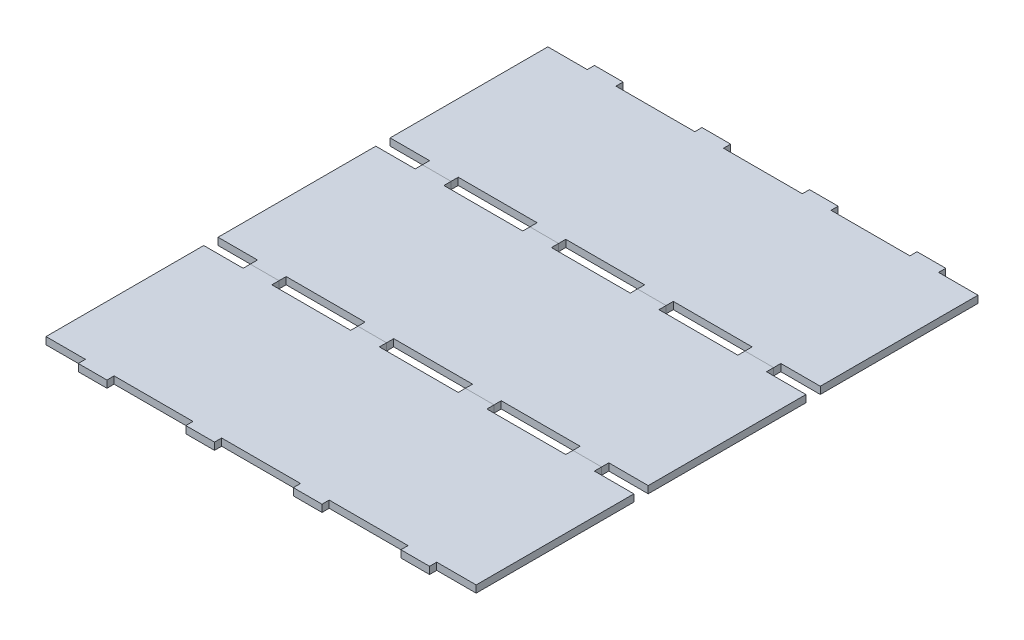
from build123d import *

# Parameters (mm, degrees)
SKETCH1_W               = 381
SKETCH1_H               = 152.4
BOSS_EXTRUDE1_DEPTH     = 6.35
SKETCH2_W               = 69.85
SKETCH2_H               = 6.35
CUT_EXTRUDE2_DEPTH      = 7.35
LPATTERN1_COUNT         = 3
LPATTERN1_PITCH         = 95.25
LPATTERN1_COL_COUNT     = 3
LPATTERN1_COL_PITCH     = 95.25
MIRROR2_COPY_1_SKETCH_W = 69.85
MIRROR2_COPY_1_SKETCH_H = 6.35
MIRROR2_COPY_1_DEPTH    = 7.35
MIRROR2_COPY_2_SKETCH_W = 69.85
MIRROR2_COPY_2_SKETCH_H = 6.35
MIRROR2_COPY_2_DEPTH    = 7.35
MIRROR2_COPY_3_SKETCH_W = 69.85
MIRROR2_COPY_3_SKETCH_H = 6.35
MIRROR2_COPY_3_DEPTH    = 7.35
MIRROR2_COPY_4_SKETCH_W = 69.85
MIRROR2_COPY_4_SKETCH_H = 6.35
MIRROR2_COPY_4_DEPTH    = 7.35
LPATTERN2_COUNT         = 3
LPATTERN2_PITCH         = 152.4


with BuildPart() as part:
    # Sketch1 → Boss-Extrude1 (new body)
    with BuildSketch(Plane(origin=(0, 0, 0), x_dir=(1, 0, 0), z_dir=(0, 1, 0))):
        Rectangle(SKETCH1_W, SKETCH1_H)
    extrude(amount=BOSS_EXTRUDE1_DEPTH)

    # Sketch2 → Cut-Extrude2 (cut, through all)
    with BuildSketch(Plane(origin=(0, 6.35, 0), x_dir=(1, 0, 0), z_dir=(0, 1, 0))):
        with Locations((0, -73.025)):
            Rectangle(SKETCH2_W, SKETCH2_H)
    cut_extrude2 = extrude(amount=-CUT_EXTRUDE2_DEPTH, mode=Mode.SUBTRACT)

    # LPattern1: Cut-Extrude2 ×3
    with Locations(*[(-i * LPATTERN1_PITCH, 0, 0) for i in range(1, LPATTERN1_COUNT)]):
        add(cut_extrude2, mode=Mode.SUBTRACT)

    # LPattern1 col: Cut-Extrude2 ×3
    with Locations(*[(i * LPATTERN1_COL_PITCH, 0, 0) for i in range(1, LPATTERN1_COL_COUNT)]):
        add(cut_extrude2, mode=Mode.SUBTRACT)

    # Mirror2: Cut-Extrude2 across plane
    add(cut_extrude2.mirror(Plane.XY), mode=Mode.SUBTRACT)

    # Mirror2 copy 1 sketch → Mirror2 copy 1 (cut, through all)
    with BuildSketch(Plane(origin=(-95.25, 6.35, 0), x_dir=(1, 0, 0), z_dir=(0, 1, 0))):
        with Locations((0, 73.025)):
            Rectangle(MIRROR2_COPY_1_SKETCH_W, MIRROR2_COPY_1_SKETCH_H)
    extrude(amount=-MIRROR2_COPY_1_DEPTH, mode=Mode.SUBTRACT)

    # Mirror2 copy 2 sketch → Mirror2 copy 2 (cut, through all)
    with BuildSketch(Plane(origin=(-190.5, 6.35, 0), x_dir=(1, 0, 0), z_dir=(0, 1, 0))):
        with Locations((0, 73.025)):
            Rectangle(MIRROR2_COPY_2_SKETCH_W, MIRROR2_COPY_2_SKETCH_H)
    extrude(amount=-MIRROR2_COPY_2_DEPTH, mode=Mode.SUBTRACT)

    # Mirror2 copy 3 sketch → Mirror2 copy 3 (cut, through all)
    with BuildSketch(Plane(origin=(95.25, 6.35, 0), x_dir=(1, 0, 0), z_dir=(0, 1, 0))):
        with Locations((0, 73.025)):
            Rectangle(MIRROR2_COPY_3_SKETCH_W, MIRROR2_COPY_3_SKETCH_H)
    extrude(amount=-MIRROR2_COPY_3_DEPTH, mode=Mode.SUBTRACT)

    # Mirror2 copy 4 sketch → Mirror2 copy 4 (cut, through all)
    with BuildSketch(Plane(origin=(190.5, 6.35, 0), x_dir=(1, 0, 0), z_dir=(0, 1, 0))):
        with Locations((0, 73.025)):
            Rectangle(MIRROR2_COPY_4_SKETCH_W, MIRROR2_COPY_4_SKETCH_H)
    extrude(amount=-MIRROR2_COPY_4_DEPTH, mode=Mode.SUBTRACT)


with BuildPart() as lpattern2_1:
    # LPattern2: pattern copy
    add(part.part.moved(Location(Vector(0, 0, 1) * (1 * LPATTERN2_PITCH))))


with BuildPart() as lpattern2_2:
    # LPattern2: pattern copy
    add(part.part.moved(Location(Vector(0, 0, 1) * (2 * LPATTERN2_PITCH))))


solid = Compound([part.part, lpattern2_1.part, lpattern2_2.part])
